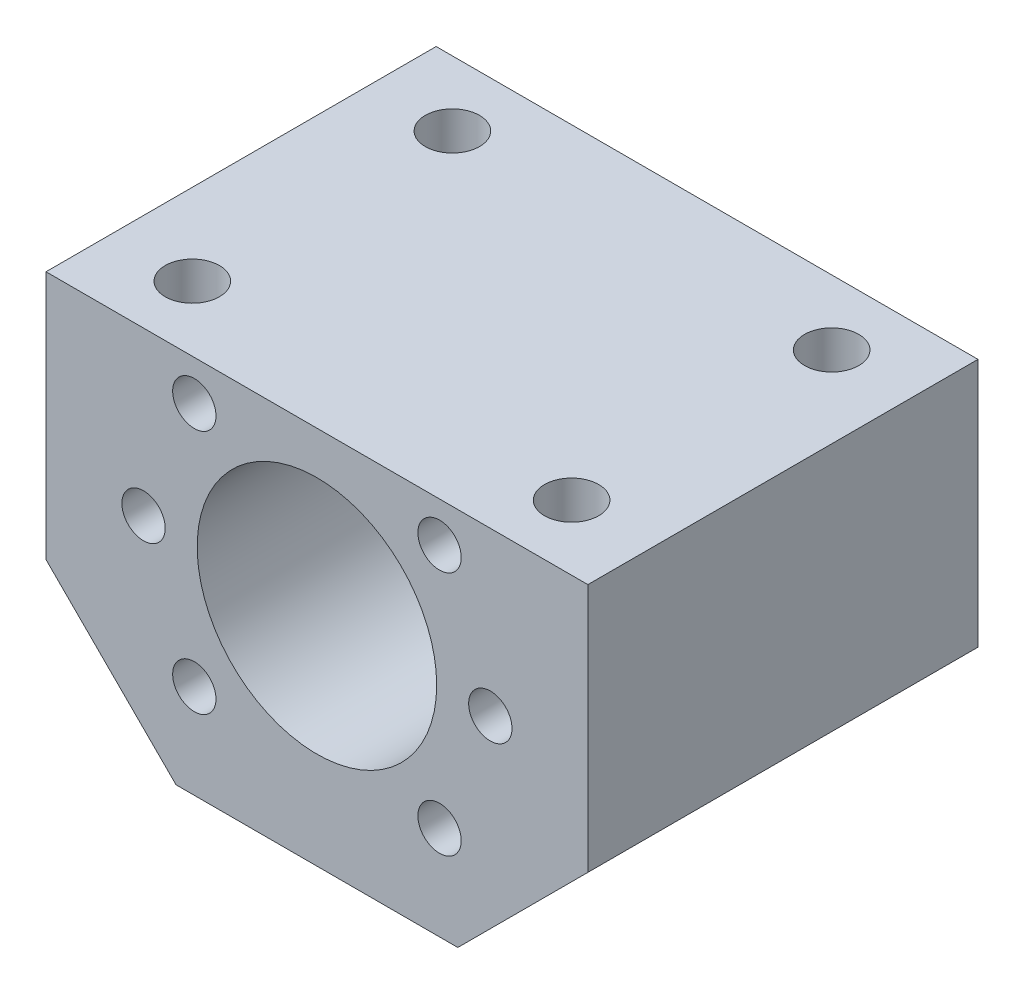
from build123d import *

# Parameters (mm, degrees)
SKETCH_1_R          = 11.05
SKETCH_1_R_2        = 2
EXTRUDE_1_DEPTH     = 36
SKETCH_3_R          = 2.5
CUT_EXTRUDE_1_DEPTH = 10


with BuildPart() as part:
    # 草图1 → 凸台-拉伸1 (new body)
    with BuildSketch(Plane.XY):
        Polygon((25, 15), (-25, 15), (-25, -8), (-13, -20), (13, -20), (25, -8), align=None)
        Circle(SKETCH_1_R, mode=Mode.SUBTRACT)
        with Locations((-16, 0)):
            Circle(SKETCH_1_R_2, mode=Mode.SUBTRACT)
        with Locations((-11.313708499, 11.313708499)):
            Circle(SKETCH_1_R_2, mode=Mode.SUBTRACT)
        with Locations((-11.313708499, -11.313708499)):
            Circle(SKETCH_1_R_2, mode=Mode.SUBTRACT)
        with Locations((11.313708499, -11.313708499)):
            Circle(SKETCH_1_R_2, mode=Mode.SUBTRACT)
        with Locations((11.313708499, 11.313708499)):
            Circle(SKETCH_1_R_2, mode=Mode.SUBTRACT)
        with Locations((16, 0)):
            Circle(SKETCH_1_R_2, mode=Mode.SUBTRACT)
    extrude(amount=EXTRUDE_1_DEPTH)

    # 草图3 → 切除-拉伸1 (cut)
    with BuildSketch(Plane(origin=(0, 15, 0), x_dir=(1, 0, 0), z_dir=(0, 1, 0))):
        with Locations((-17.5, -6)):
            Circle(SKETCH_3_R)
        with Locations((-17.5, -30)):
            Circle(SKETCH_3_R)
        with Locations((17.5, -30)):
            Circle(SKETCH_3_R)
        with Locations((17.5, -6)):
            Circle(SKETCH_3_R)
    extrude(amount=-CUT_EXTRUDE_1_DEPTH, mode=Mode.SUBTRACT)


solid = part.part
